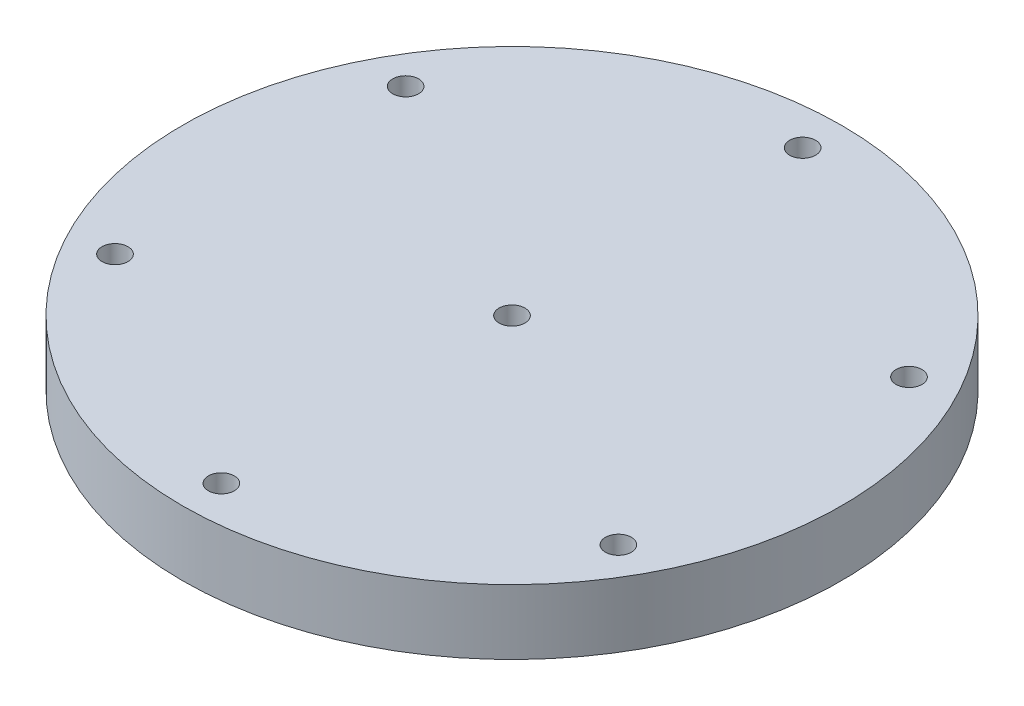
from build123d import *

# Parameters (mm, degrees)
SKETCH1_R           = 50.8
BOSS_EXTRUDE1_DEPTH = 10
SKETCH2_R           = 38.1
SKETCH2_R_2         = 36.5
CUT_EXTRUDE1_DEPTH  = 2
SKETCH3_R           = 2
CUT_EXTRUDE2_DEPTH  = 14


with BuildPart() as part:
    # Sketch1 → Boss-Extrude1 (new body)
    with BuildSketch(Plane(origin=(0, 0, 0), x_dir=(1, 0, 0), z_dir=(0, 1, 0))):
        Circle(SKETCH1_R)
    extrude(amount=BOSS_EXTRUDE1_DEPTH)

    # Sketch2 → Cut-Extrude1 (cut)
    with BuildSketch(Plane.XZ):
        Circle(SKETCH2_R)
        Circle(SKETCH2_R_2, mode=Mode.SUBTRACT)
    extrude(amount=-CUT_EXTRUDE1_DEPTH, mode=Mode.SUBTRACT)

    # Sketch3 → Cut-Extrude2 (cut)
    with BuildSketch(Plane(origin=(0, 10, 0), x_dir=(1, 0, 0), z_dir=(0, 1, 0))):
        Circle(SKETCH3_R)
        with Locations((0, 44.8)):
            Circle(SKETCH3_R)
        with Locations((38.79793809, 22.4)):
            Circle(SKETCH3_R)
        with Locations((38.79793809, -22.4)):
            Circle(SKETCH3_R)
        with Locations((0, -44.8)):
            Circle(SKETCH3_R)
        with Locations((-38.79793809, -22.4)):
            Circle(SKETCH3_R)
        with Locations((-38.79793809, 22.4)):
            Circle(SKETCH3_R)
    extrude(amount=-CUT_EXTRUDE2_DEPTH, mode=Mode.SUBTRACT)


solid = part.part
